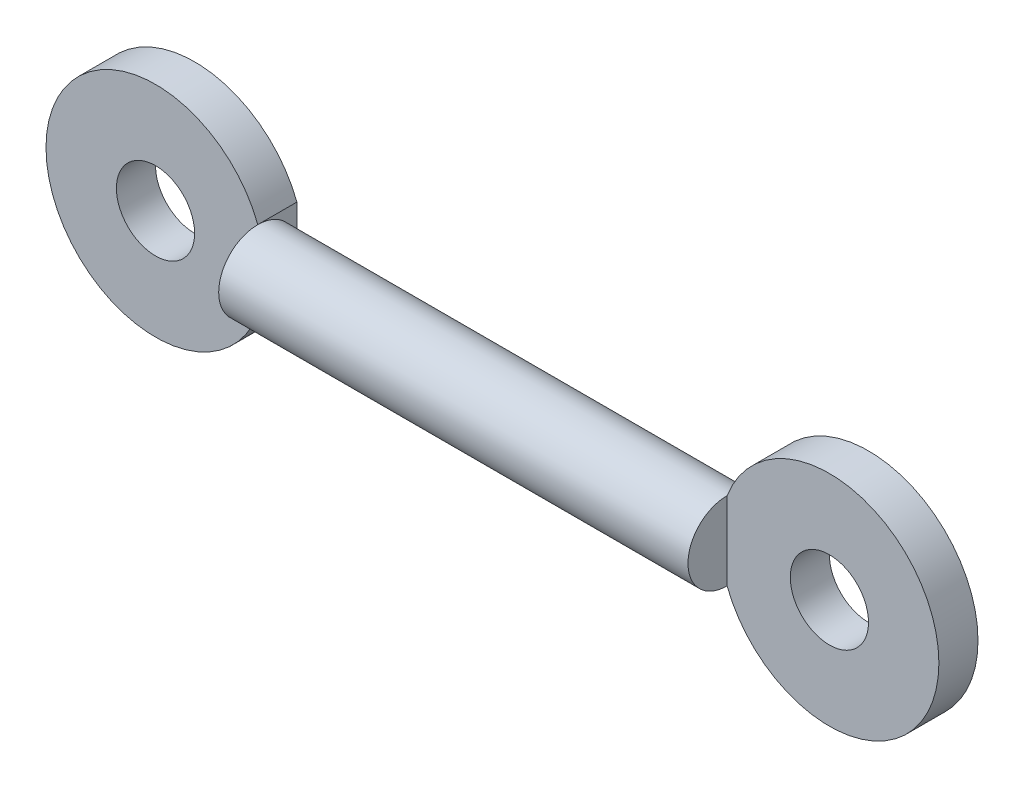
from build123d import *

# Parameters (mm, degrees)
SKETCH1_W           = 30
SKETCH1_H           = 2.5
SKETCH3_R           = 2.5
BOSS_EXTRUDE2_DEPTH = 2.5


with BuildPart() as part:
    # Sketch1 → Revolve-Thin1 (revolve)
    with BuildSketch(Plane.XY):
        with Locations((0, 1.25)):
            Rectangle(SKETCH1_W, SKETCH1_H)
    revolve(axis=Axis((-15, 0, 0), (1, 0, 0)))

    # Sketch3 → Boss-Extrude2 (add)
    with BuildSketch(Plane.XY):
        with BuildLine():
            Line((15, 2.5), (15, -2.5))
            ThreePointArc((15, -2.5), (28.538348415, 0), (15, 2.5))
        make_face()
        with Locations((21.538348415, 0)):
            Circle(SKETCH3_R, mode=Mode.SUBTRACT)
        with BuildLine():
            Line((-15, -2.5), (-15, 2.5))
            ThreePointArc((-15, 2.5), (-28.538348415, 0), (-15, -2.5))
        make_face()
        with Locations((-21.538348415, 0)):
            Circle(SKETCH3_R, mode=Mode.SUBTRACT)
    extrude(amount=-BOSS_EXTRUDE2_DEPTH)


solid = part.part
